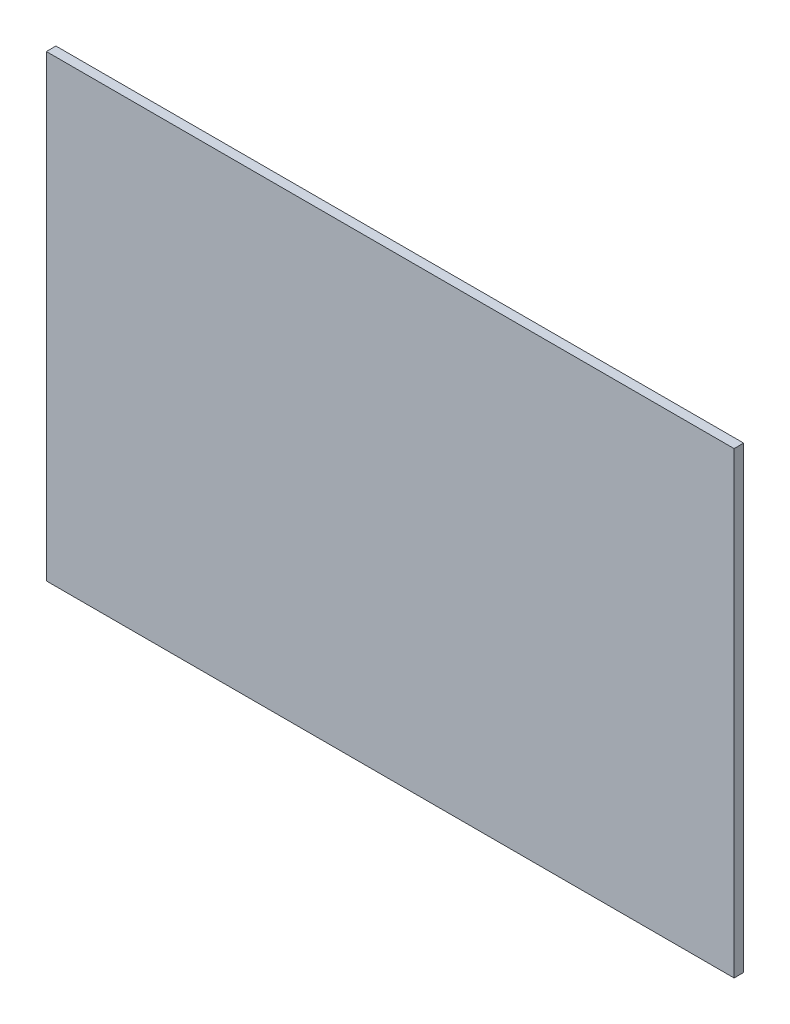
from build123d import *

# Parameters (mm, degrees)
SKETCH1_W      = 1828.8
SKETCH1_H      = 1219.2
EXTRUDE1_DEPTH = 25.4


with BuildPart() as part:
    # Sketch1 → Extrude1 (new body)
    with BuildSketch(Plane.XY):
        with Locations((809.683880171, 535.836733238)):
            Rectangle(SKETCH1_W, SKETCH1_H)
    extrude(amount=EXTRUDE1_DEPTH)


solid = part.part
